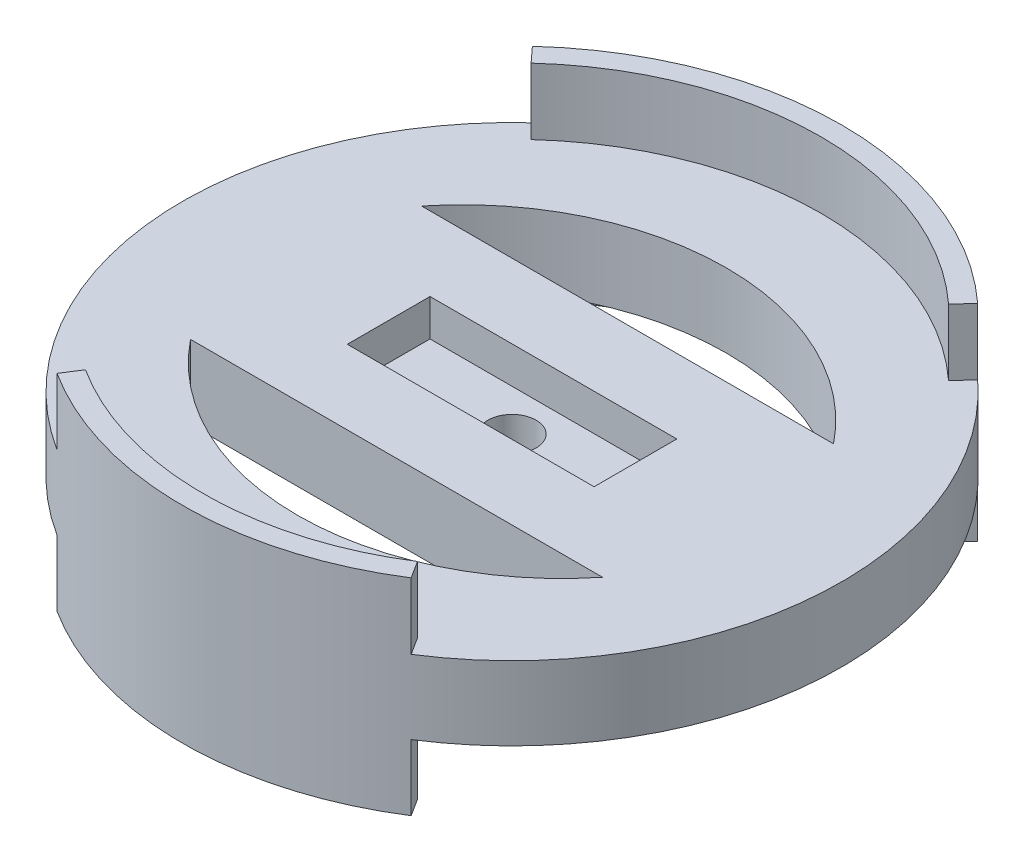
from build123d import *

# Parameters (mm, degrees)
SKETCH1_R           = 50.8
SKETCH1_W           = 38.0365
SKETCH1_H           = 12.7508
BOSS_EXTRUDE1_DEPTH = 5.6642
BOSS_EXTRUDE2_START = -5.715
SKETCH1_3_R         = 50.8
SKETCH1_3_R_2       = 3.71475
BOSS_EXTRUDE2_DEPTH = 5.715
BOSS_EXTRUDE3_DEPTH = 15.875
CUT_EXTRUDE1_DEPTH  = 76.001448


with BuildPart() as part:
    # Sketch1 → Boss-Extrude1 (new body)
    with BuildSketch(Plane(origin=(0, 0, 0), x_dir=(1, 0, 0), z_dir=(0, 1, 0))):
        Circle(SKETCH1_R)
        Rectangle(SKETCH1_W, SKETCH1_H, mode=Mode.SUBTRACT)
    extrude(amount=BOSS_EXTRUDE1_DEPTH)

    # Sketch1_3 → Boss-Extrude2 (add)
    with BuildSketch(Plane(origin=(0, 0, 0), x_dir=(1, 0, 0), z_dir=(0, 1, 0)).offset(BOSS_EXTRUDE2_START)):
        Circle(SKETCH1_3_R)
        Circle(SKETCH1_3_R_2, mode=Mode.SUBTRACT)
    extrude(amount=BOSS_EXTRUDE2_DEPTH)

    # Sketch2 → Boss-Extrude3 (add, symmetric)
    with BuildSketch(Plane(origin=(0, 0, 0), x_dir=(1, 0, 0), z_dir=(0, 1, 0))):
        with BuildLine():
            Line((-32.174984, 35.112833), (-34.319983, 37.453689))
            ThreePointArc((-34.319983, 37.453689), (0, 50.8), (34.319983, 37.453689))
            Line((34.319983, 37.453689), (32.174984, 35.112833))
            ThreePointArc((32.174984, 35.112833), (0, 47.625), (-32.174984, 35.112833))
        make_face()
        with BuildLine():
            Line((-25.588894, -40.166518), (-27.29482, -42.844285))
            ThreePointArc((-27.29482, -42.844285), (0, -50.8), (27.29482, -42.844285))
            Line((27.29482, -42.844285), (25.588894, -40.166518))
            ThreePointArc((25.588894, -40.166518), (0, -47.625), (-25.588894, -40.166518))
        make_face()
    extrude(amount=BOSS_EXTRUDE3_DEPTH, both=True)

    # Sketch3 → Cut-Extrude1 (cut, through all)
    with BuildSketch(Plane(origin=(0, 5.6642, 0), x_dir=(1, 0, 0), z_dir=(0, 1, 0))):
        with BuildLine():
            Line((-31.75, 17.8054), (31.75, 17.8054))
            ThreePointArc((31.75, 17.8054), (0, 33.0454), (-31.75, 17.8054))
        make_face()
        with BuildLine():
            Line((-31.75, -17.8054), (31.75, -17.8054))
            ThreePointArc((31.75, -17.8054), (0, -33.0454), (-31.75, -17.8054))
        make_face()
    extrude(amount=-CUT_EXTRUDE1_DEPTH, mode=Mode.SUBTRACT)


solid = part.part
